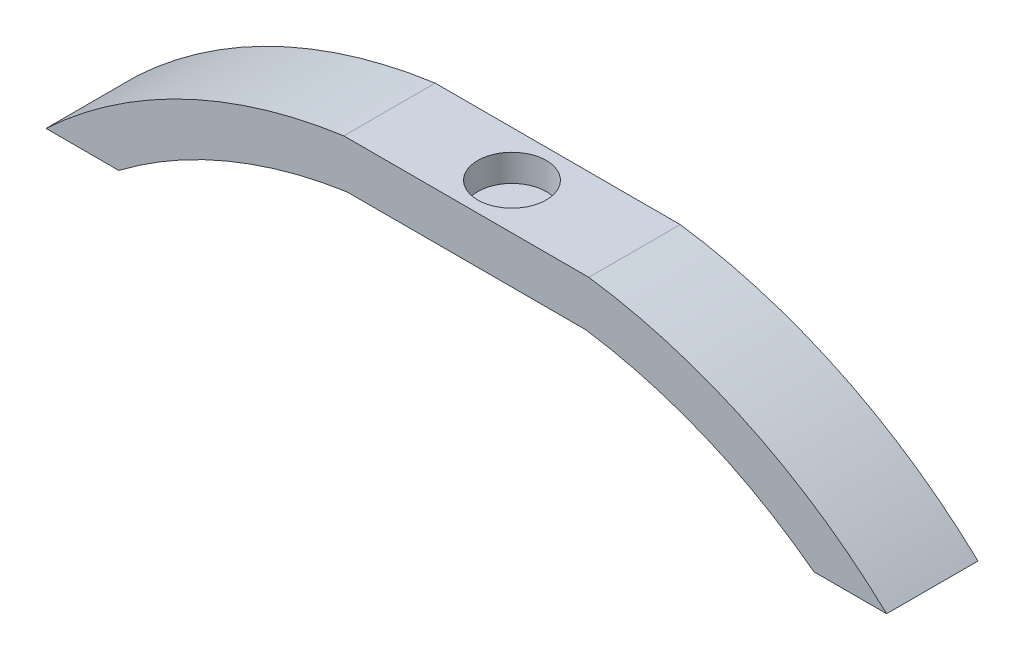
from build123d import *

# Parameters (mm, degrees)
BOSS_EXTRUDE1_DEPTH = 10.16
SKETCH2_R           = 3.81
CUT_EXTRUDE1_DEPTH  = 3


with BuildPart() as part:
    # Sketch1 → Boss-Extrude1 (new body)
    with BuildSketch(Plane.XY):
        with BuildLine():
            Line((-13.62, 59.991671726), (13.62, 59.991671726))
            ThreePointArc((13.62, 59.991671726), (31.406367433, 54.640733913), (46.735, 44.151671726))
            Line((46.735, 44.151671726), (38.650315963, 44.151671726))
            ThreePointArc((38.650315963, 44.151671726), (26.621127245, 51.066108705), (13.25027751, 54.771671726))
            Line((13.25027751, 54.771671726), (-13.25027751, 54.771671726))
            ThreePointArc((-13.25027751, 54.771671726), (-26.621127245, 51.066108705), (-38.650315963, 44.151671726))
            Line((-38.650315963, 44.151671726), (-46.735, 44.151671726))
            ThreePointArc((-46.735, 44.151671726), (-31.406367433, 54.640733913), (-13.62, 59.991671726))
        make_face()
    extrude(amount=BOSS_EXTRUDE1_DEPTH)

    # Sketch2 → Cut-Extrude1 (cut)
    with BuildSketch(Plane(origin=(0, 59.991671726, 0), x_dir=(1, 0, 0), z_dir=(0, 1, 0))):
        with Locations((0, -5.08)):
            Circle(SKETCH2_R)
    extrude(amount=-CUT_EXTRUDE1_DEPTH, mode=Mode.SUBTRACT)


solid = part.part
